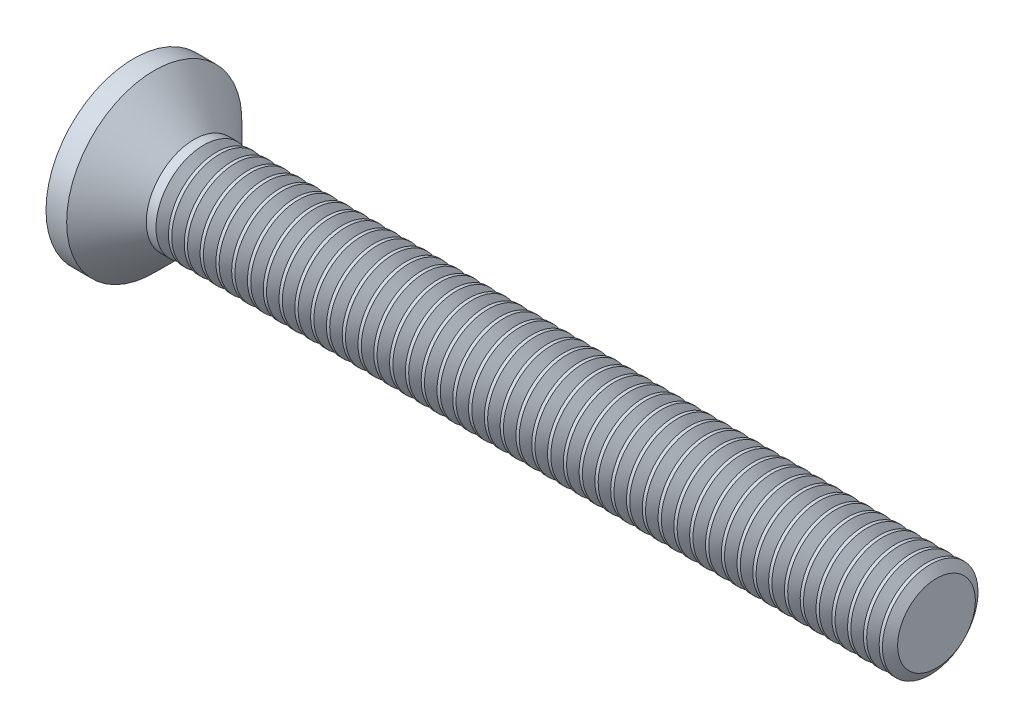
from build123d import *

# Parameters (mm, degrees)
SKETCH3_W         = 0.83
SKETCH3_H         = 3.44
SKETCH4_W         = 0.415
SKETCH4_H         = 0.415
CIRPATTERN1_COUNT = 2
CIRPATTERN1_ANGLE = 90
THDSCHPAT_COUNT   = 47
THDSCHPAT_PITCH   = 0.495652174


with BuildPart() as part:
    # BodySke → Base-Revolve (revolve)
    with BuildSketch(Plane.XY):
        with BuildLine():
            Line((0, 0), (25.727669073, 0))
            Line((25.727669073, 0), (25.727669073, 1.5))
            Line((25.727669073, 1.5), (2.427669073, 1.5))
            Line((2.427669073, 1.5), (1.177669073, 2.75))
            Line((1.177669073, 2.75), (0.529956332, 2.75))
            ThreePointArc((0.529956332, 2.75), (0.133696843, 1.400299407), (0, 0))
        make_face()
    revolve(axis=Axis((-15.875, 0, 0), (1, 0, 0)))

    # Sketch3 → Cross section 0
    with BuildSketch(Plane(origin=(0, 0, 0), x_dir=(0, 0, -1), z_dir=(1, 0, 0))):
        Rectangle(SKETCH3_W, SKETCH3_H)
    # Sketch4 → Cross section 1
    with BuildSketch(Plane(origin=(2.33, 0, 0), x_dir=(0, 0, -1), z_dir=(1, 0, 0))):
        Rectangle(SKETCH4_W, SKETCH4_H)
    cross = loft(mode=Mode.SUBTRACT)

    # CirPattern1: Cross ×2 about axis
    cirpattern1_axis = Axis((0, 0, 0), (1, 0, 0))
    for i in range(1, CIRPATTERN1_COUNT):
        add(cross.rotate(cirpattern1_axis, i * CIRPATTERN1_ANGLE / (CIRPATTERN1_COUNT - 1)), mode=Mode.SUBTRACT)

    # ThdSchSke → ThreadSchematic (revolve, cut)
    with BuildSketch(Plane.XY):
        Polygon((2.927669073, -1.2195), (2.731260858, -1.5), (2.731260858, -1.875), (3.124077287, -1.875), (3.124077287, -1.5), align=None)
    threadschematic = revolve(axis=Axis((-3.175, 0, 0), (1, 0, 0)), mode=Mode.SUBTRACT)

    # ThdSchPat: ThreadSchematic ×47
    with Locations(*[(i * THDSCHPAT_PITCH, 0, 0) for i in range(1, THDSCHPAT_COUNT)]):
        add(threadschematic, mode=Mode.SUBTRACT)


solid = part.part
